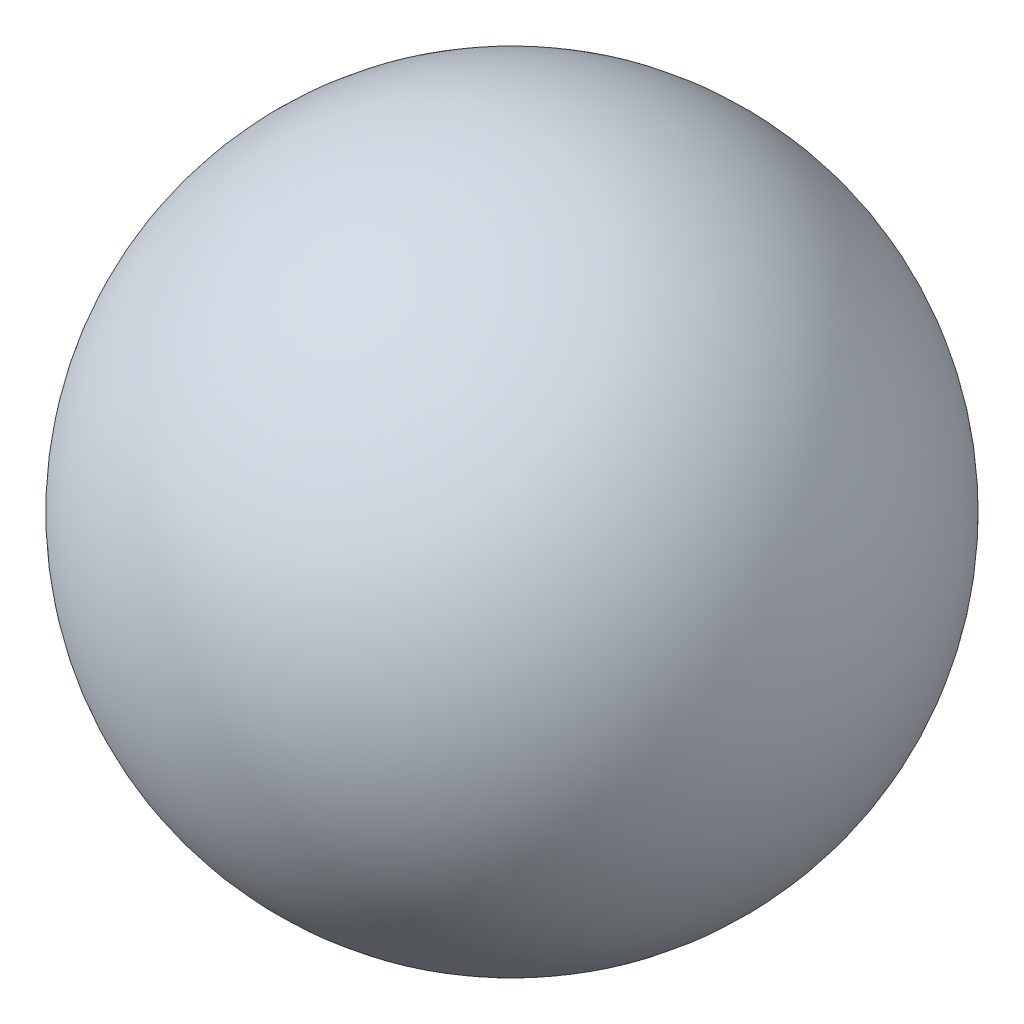
from build123d import *


with BuildPart() as part:
    # Skizze1 → Rotation1 (revolve)
    with BuildSketch(Plane.XY):
        with BuildLine():
            Line((0, -10), (0, 10))
            ThreePointArc((0, 10), (10, 0), (0, -10))
        make_face()
    revolve(axis=Axis((0, -10, 0), (0, 1, 0)))


solid = part.part
